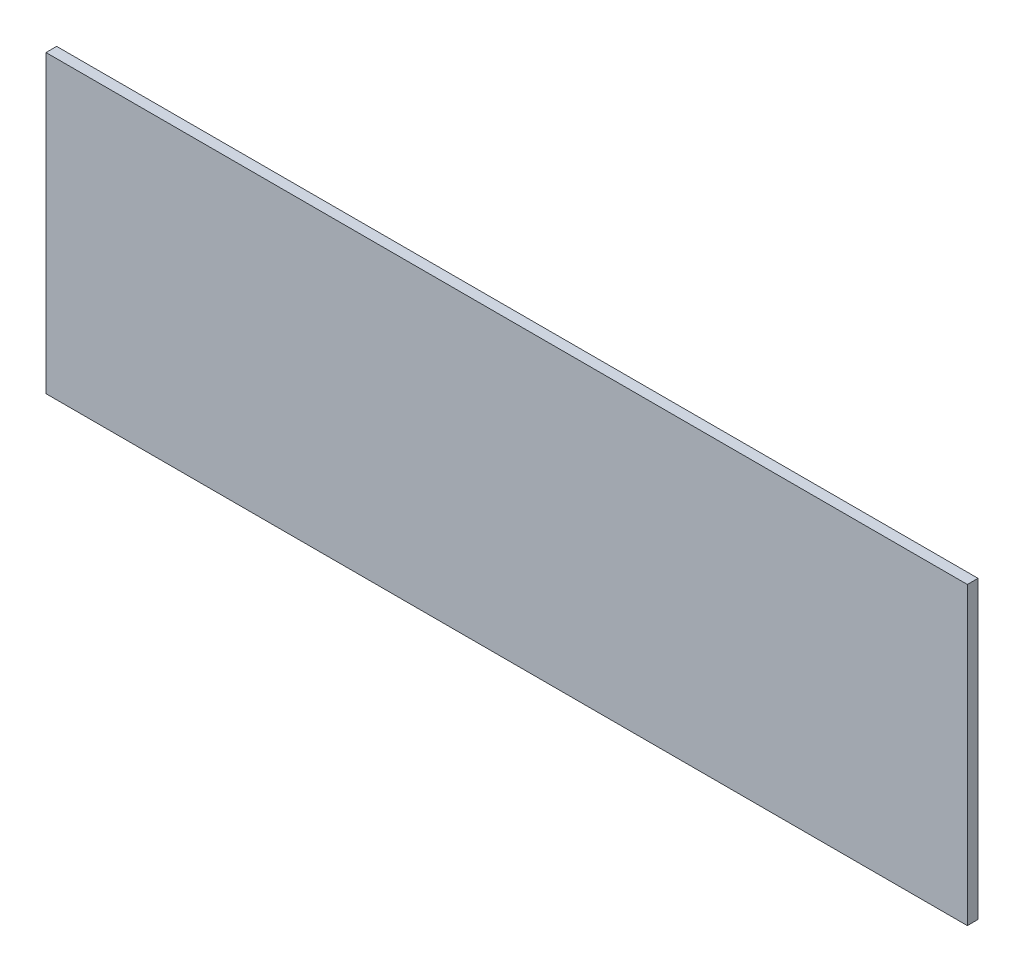
from build123d import *

# Parameters (mm, degrees)
SKETCH1_W           = 259.398086837
SKETCH1_H           = 83.19083402
BOSS_EXTRUDE1_DEPTH = 3


with BuildPart() as part:
    # Sketch1 → Boss-Extrude1 (new body)
    with BuildSketch(Plane.XY):
        with Locations((960.875777949, 318.40458299)):
            Rectangle(SKETCH1_W, SKETCH1_H)
    extrude(amount=-BOSS_EXTRUDE1_DEPTH)


solid = part.part
